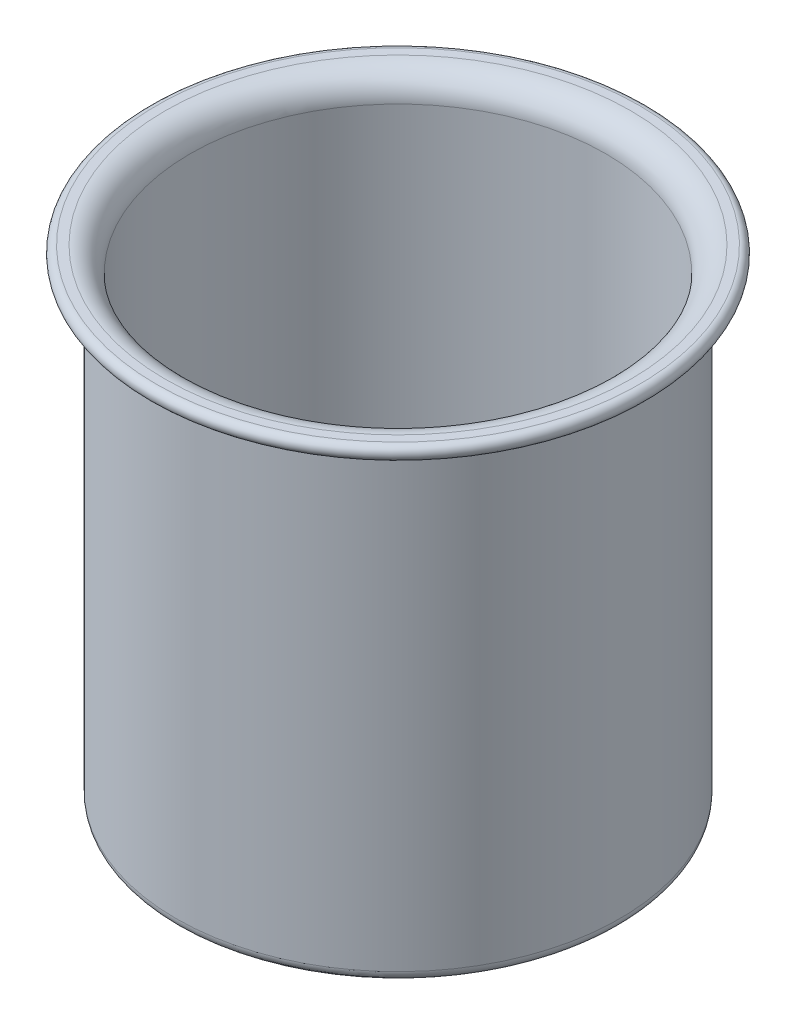
from build123d import *


with BuildPart() as part:
    # Sketch1 → Revolve1 (revolve)
    with BuildSketch(Plane.XY, mode=Mode.PRIVATE) as revolve1_sk:
        with BuildLine():
            Line((0, 0), (-59.5, 0))
            ThreePointArc((-59.5, 0), (-61.621320344, 0.878679656), (-62.5, 3))
            Line((-62.5, 3), (-62.5, 129))
            ThreePointArc((-62.5, 129), (-63.378679656, 131.121320344), (-65.5, 132))
            Line((-65.5, 132), (-67.983599332, 132))
            ThreePointArc((-67.983599332, 132), (-69.983599332, 134), (-67.983599332, 136))
            Line((-67.983599332, 136), (-65.5, 136))
            ThreePointArc((-65.5, 136), (-60.550252532, 133.949747468), (-58.5, 129))
            Line((-58.5, 129), (-58.5, 4))
            Line((-58.5, 4), (0, 4))
            Line((0, 4), (0, 0))
        make_face()
    revolve(revolve1_sk.sketch.rotate(Axis((0, 0, 0), (0, 1, 0)), 270), axis=Axis((0, 0, 0), (0, 1, 0)))


solid = part.part
